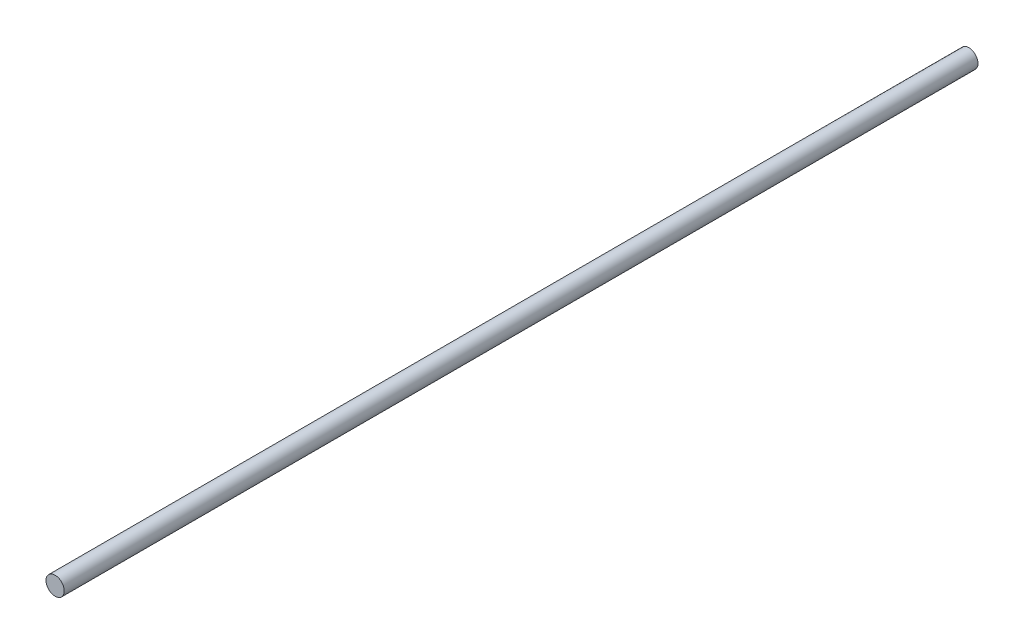
from build123d import *

# Parameters (mm, degrees)
SKETCH1_R           = 2
BOSS_EXTRUDE1_DEPTH = 100


with BuildPart() as part:
    # Sketch1 → Boss-Extrude1 (new body, symmetric)
    with BuildSketch(Plane.XY):
        Circle(SKETCH1_R)
    extrude(amount=BOSS_EXTRUDE1_DEPTH, both=True)


solid = part.part
